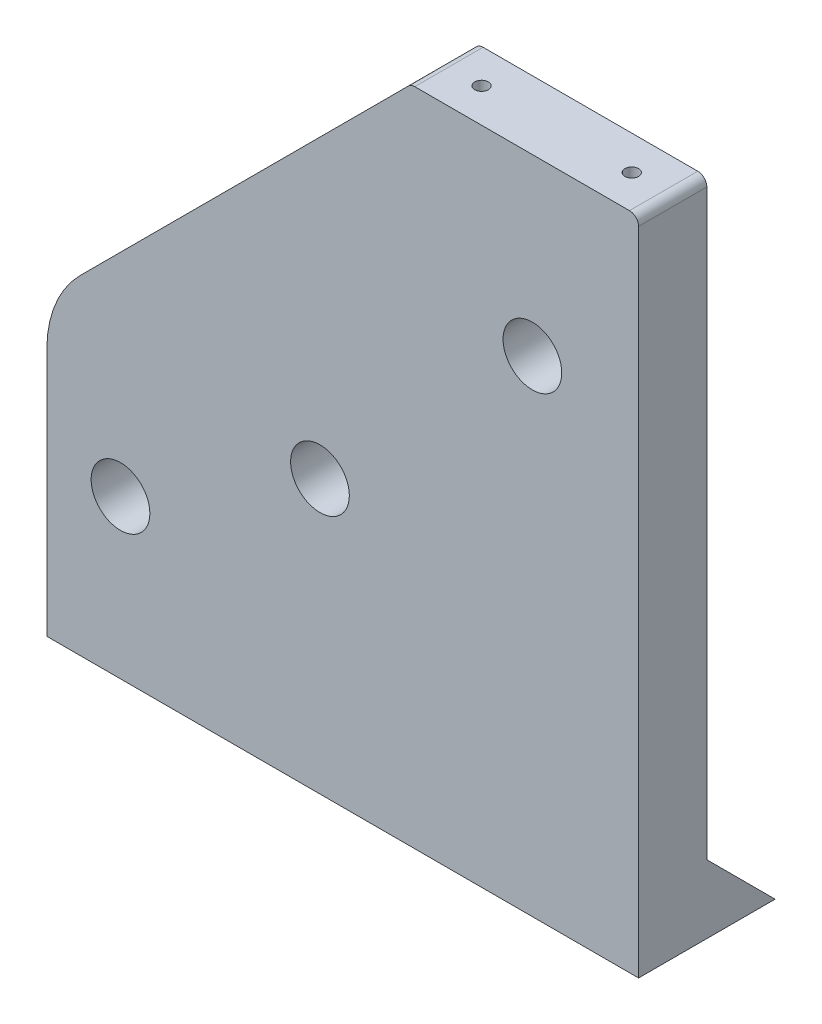
from build123d import *

# Parameters (mm, degrees)
SKETCH1_W           = 130
SKETCH1_H           = 145
SKETCH1_R           = 6.45
BOSS_EXTRUDE1_DEPTH = 15
CHAMFER1_SIZE       = 80
FILLET2_R           = 25
FILLET1_R           = 2
BOSS_EXTRUDE2_DEPTH = 130
SKETCH3_R           = 2.75
CUT_EXTRUDE1_DEPTH  = 45
SKETCH4_R           = 1.5
CUT_EXTRUDE2_DEPTH  = 25


with BuildPart() as part:
    # Sketch1 → Boss-Extrude1 (new body)
    with BuildSketch(Plane.XY):
        with Locations((65, 72.5)):
            Rectangle(SKETCH1_W, SKETCH1_H)
        with Locations((60, 60)):
            Circle(SKETCH1_R, mode=Mode.SUBTRACT)
        with Locations((106.669047558, 106.669047558)):
            Circle(SKETCH1_R, mode=Mode.SUBTRACT)
        with Locations((16.179114569, 34.7)):
            Circle(SKETCH1_R, mode=Mode.SUBTRACT)
    extrude(amount=BOSS_EXTRUDE1_DEPTH)

    # Chamfer1
    chamfer1_edges = [part.edges().sort_by_distance(p)[0] for p in [
        (0, 145, 7.5),
    ]]
    chamfer(chamfer1_edges, length=CHAMFER1_SIZE)

    # Fillet2
    fillet2_edges = [part.edges().sort_by_distance(p)[0] for p in [
        (0, 65, 7.5),
    ]]
    fillet(fillet2_edges, radius=FILLET2_R)

    # Fillet1
    fillet1_edges = [part.edges().sort_by_distance(p)[0] for p in [
        (80, 145, 7.5),
        (130, 145, 7.5),
    ]]
    fillet(fillet1_edges, radius=FILLET1_R)

    # Sketch2 → Boss-Extrude2 (add, through all)
    with BuildSketch(Plane(origin=(130, 0, 0), x_dir=(0, 0, -1), z_dir=(1, 0, 0))):
        Polygon((0, 15), (15, 0), (0, 0), align=None)
    extrude(amount=-BOSS_EXTRUDE2_DEPTH)

    # Sketch3 → Cut-Extrude1 (cut)
    with BuildSketch(Plane.XZ):
        with Locations((35, 7.5)):
            Circle(SKETCH3_R)
        with Locations((105, 7.5)):
            Circle(SKETCH3_R)
    extrude(amount=-CUT_EXTRUDE1_DEPTH, mode=Mode.SUBTRACT)

    # Sketch4 → Cut-Extrude2 (cut)
    with BuildSketch(Plane(origin=(0, 145, 0), x_dir=(1, 0, 0), z_dir=(0, 1, 0))):
        with Locations((121, -7.5)):
            Circle(SKETCH4_R)
        with Locations((88, -7.5)):
            Circle(SKETCH4_R)
    extrude(amount=-CUT_EXTRUDE2_DEPTH, mode=Mode.SUBTRACT)


solid = part.part
